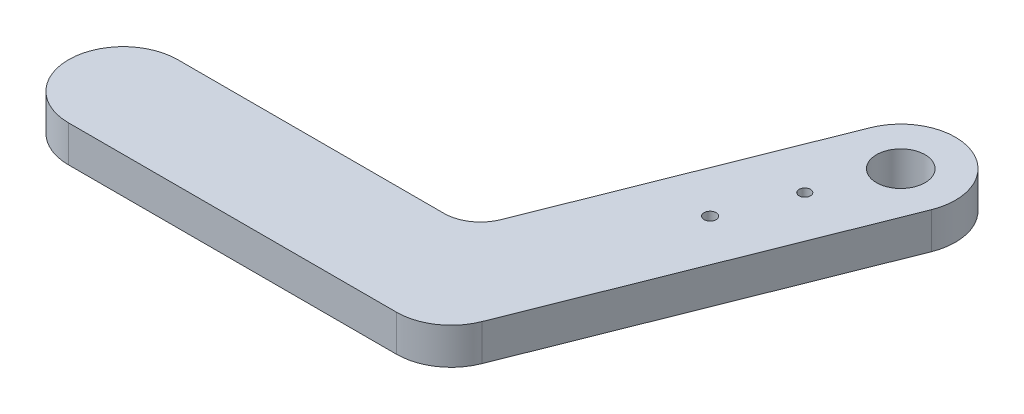
from build123d import *

# Parameters (mm, degrees)
SKETCH1_R           = 2
SKETCH1_R_2         = 0.5
SKETCH1_R_3         = 0.467640607
BOSS_EXTRUDE1_DEPTH = 3


with BuildPart() as part:
    # Sketch1 → Boss-Extrude1 (new body)
    with BuildSketch(Plane(origin=(0, 0, 0), x_dir=(1, 0, 0), z_dir=(0, 1, 0))):
        with BuildLine():
            Line((20.788979156, 19.455191892), (10.263863139, -7.030123526))
            ThreePointArc((10.263863139, -7.030123526), (8.608988058, -9.091727344), (6.08197123, -9.868263103))
            Line((6.08197123, -9.868263103), (-20.91802877, -9.868263103))
            ThreePointArc((-20.91802877, -9.868263103), (-25.41802877, -5.368263103), (-20.91802877, -0.868263103))
            Line((-20.91802877, -0.868263103), (0.991919338, -0.868263103))
            ThreePointArc((0.991919338, -0.868263103), (2.676597223, -0.350572597), (3.779847277, 1.023829948))
            Line((3.779847277, 1.023829948), (12.42519534, 22.77891274))
            ThreePointArc((12.42519534, 22.77891274), (18.268947672, 25.298944224), (20.788979156, 19.455191892))
        make_face()
        with Locations((16.607087248, 21.117052316)):
            Circle(SKETCH1_R, mode=Mode.SUBTRACT)
        with Locations((12.144068754, 9.886349269)):
            Circle(SKETCH1_R_2, mode=Mode.SUBTRACT)
        with Locations((14.359882652, 15.462205147)):
            Circle(SKETCH1_R_3, mode=Mode.SUBTRACT)
    extrude(amount=BOSS_EXTRUDE1_DEPTH)


solid = part.part
